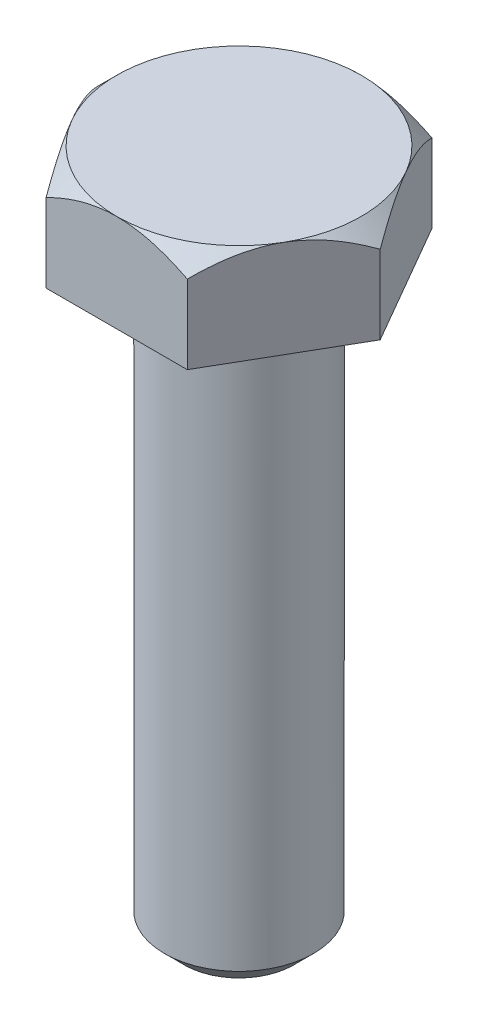
from build123d import *

# Parameters (mm, degrees)
EXTRUDE_1_DEPTH     = 5
SKETCH_8_OUTSIDE_W  = 22.464
SKETCH_8_OUTSIDE_H  = 20.522
SKETCH_8_OUTSIDE_R  = 6.278684177
CUT_EXTRUDE_1_DEPTH = 1
CUT_EXTRUDE_1_DRAFT = -45
SKETCH_9_R          = 3.825
BOLT_LENGTH_DEPTH   = 30
FILLET_1_R          = 1
CHAMFER_1_SIZE      = 1


with BuildPart() as part:
    # Эскиз6 → Бобышка-Вытянуть1 (new body)
    with BuildSketch(Plane(origin=(0, 0, 0), x_dir=(1, 0, 0), z_dir=(0, 1, 0))):
        Polygon((7.25, 0), (3.625, 6.278684177), (-3.625, 6.278684177), (-7.25, 0), (-3.625, -6.278684177), (3.625, -6.278684177), align=None)
    extrude(amount=EXTRUDE_1_DEPTH)


with BuildPart() as cut_extrude_1_tool:
    # Эскиз8 outside → Вырез-Вытянуть1 (with draft: the straight prism first)
    with BuildSketch(Plane(origin=(0, 5, 0), x_dir=(1, 0, 0), z_dir=(0, 1, 0))):
        Rectangle(SKETCH_8_OUTSIDE_W, SKETCH_8_OUTSIDE_H)
        Circle(SKETCH_8_OUTSIDE_R, mode=Mode.SUBTRACT)
    extrude(amount=-CUT_EXTRUDE_1_DEPTH)
    # Вырез-Вытянуть1: the draft: its side faces are tilted about the plane it starts from
    cut_extrude_1_sides = [cut_extrude_1_tool.faces().sort_by_distance(p)[0] for p in [
        (0, 4.5, 10.261),
        (11.232, 4.5, 0),
        (0, 4.5, -10.261),
        (-11.232, 4.5, 0),
        (-6.278684177, 4.5, 0),
    ]]
    draft(cut_extrude_1_sides, Plane(origin=(0, 5, 0), x_dir=(1, 0, 0), z_dir=(0, 1, 0)), CUT_EXTRUDE_1_DRAFT)


with BuildPart() as part_1:
    add(part.part)

    # Вырез-Вытянуть1: cut by cut_extrude_1_tool
    add(cut_extrude_1_tool.part, mode=Mode.SUBTRACT)

    # Эскиз9 → bolt length (add)
    with BuildSketch(Plane.XZ):
        with Locations(Location((0, 0, 0), (0, 0, 90))):  # turned: the seam where the file's is
            Circle(SKETCH_9_R)
    extrude(amount=BOLT_LENGTH_DEPTH)

    # Скругление1
    fillet_1_edges = [part_1.edges().sort_by_distance(p)[0] for p in [
        (0, 0, -3.825),
    ]]
    fillet(fillet_1_edges, radius=FILLET_1_R)

    # Фаска1
    chamfer_1_edges = [part_1.edges().sort_by_distance(p)[0] for p in [
        (0, -30, -3.825),
    ]]
    chamfer(chamfer_1_edges, length=CHAMFER_1_SIZE)


solid = part_1.part
